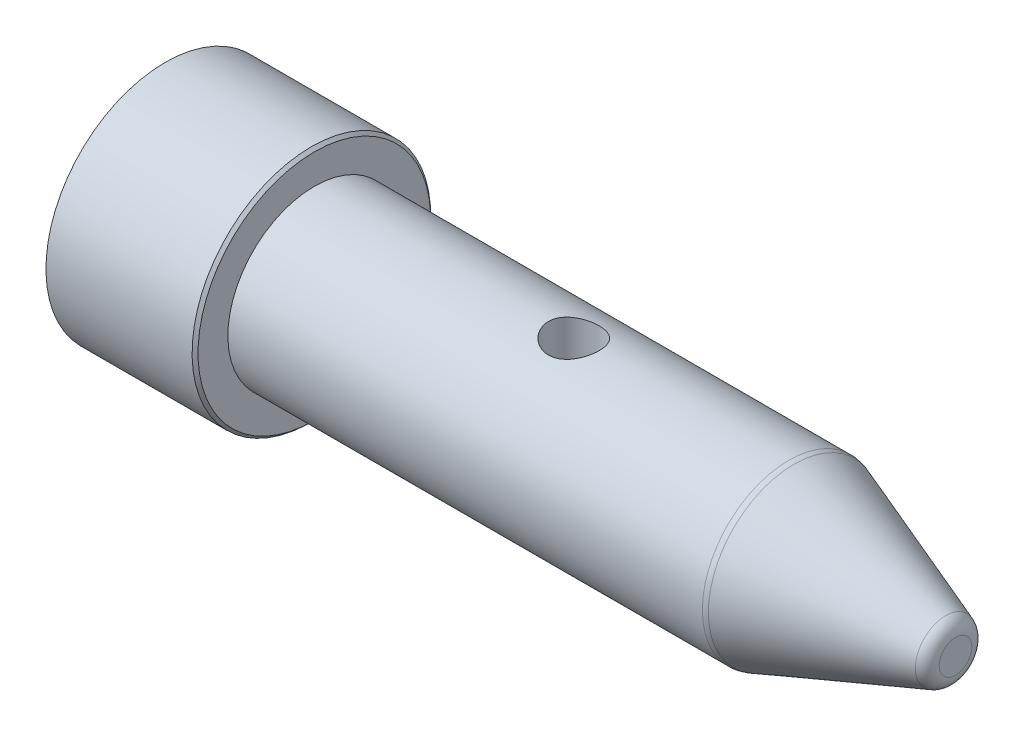
from build123d import *

# Parameters (mm, degrees)
FASE1_SIZE                      = 1
VERRUNDUNG1_R                   = 5
SKIZZE2_R                       = 8.5
SCHNITT_LINEAR_AUSTRAGEN1_DEPTH = 55


with BuildPart() as part:
    # Skizze1 → Rotation1 (revolve)
    with BuildSketch(Plane.XY):
        Polygon((0, 40), (50, 40), (50, 29), (210, 29), (265, 8.981637115), (265, 0), (0, 0), (-3, 0), (-3, 10), (0, 10), align=None)
    revolve(axis=Axis((265, 0, 0), (-1, 0, 0)))

    # Fase1
    fase1_edges = [part.edges().sort_by_distance(p)[0] for p in [
        (50, -40, 0),
    ]]
    chamfer(fase1_edges, length=FASE1_SIZE)

    # Verrundung1
    verrundung1_edges = [part.edges().sort_by_distance(p)[0] for p in [
        (265, -8.981637115, 0),
        (210, -29, 0),
    ]]
    fillet(verrundung1_edges, radius=VERRUNDUNG1_R)

    # Skizze2 → Schnitt-Linear austragen1 (cut, symmetric)
    with BuildSketch(Plane(origin=(0, 0, 0), x_dir=(1, 0, 0), z_dir=(0, 1, 0))):
        with Locations(Location((137, 0, 0), (0, 0, 270))):  # turned: the seam where the file's is
            Circle(SKIZZE2_R)
    extrude(amount=SCHNITT_LINEAR_AUSTRAGEN1_DEPTH, both=True, mode=Mode.SUBTRACT)


solid = part.part
